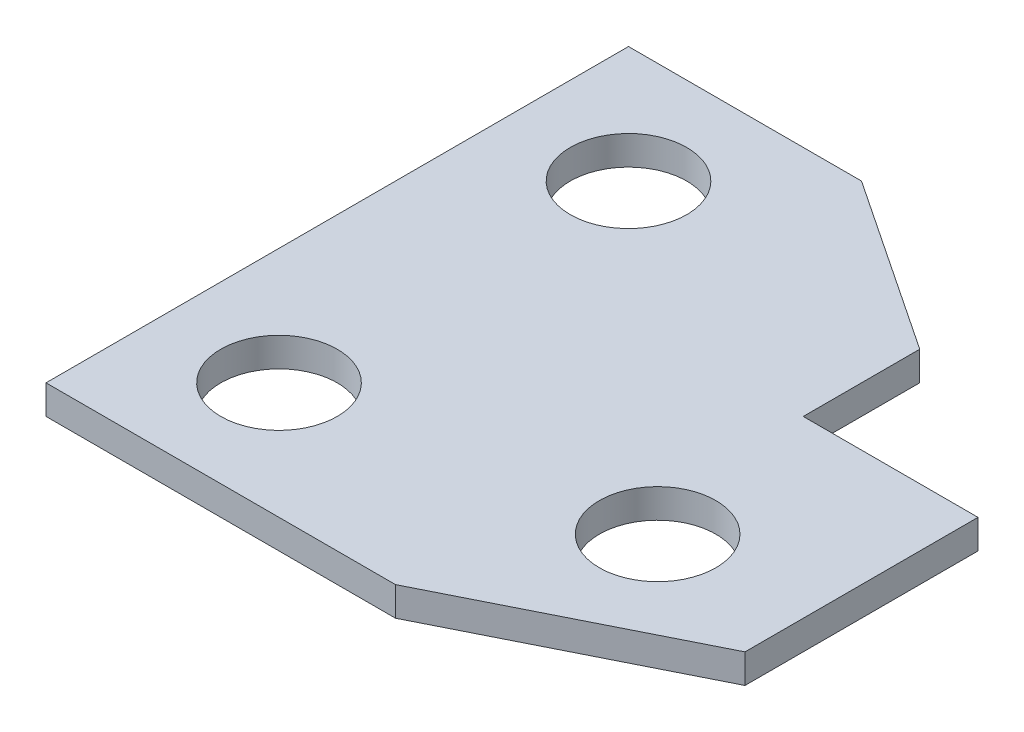
from build123d import *

# Parameters (mm, degrees)
SKETCH1_R           = 10
BOSS_EXTRUDE1_DEPTH = 5


with BuildPart() as part:
    # Sketch1 → Boss-Extrude1 (new body)
    with BuildSketch(Plane(origin=(0, 0, 0), x_dir=(1, 0, 0), z_dir=(0, 1, 0))):
        Polygon((0, 0), (60, 0), (100, 20), (100, 60), (70, 60), (70, 80), (40, 100), (0, 100), align=None)
        with Locations((20, 80)):
            Circle(SKETCH1_R, mode=Mode.SUBTRACT)
        with Locations((20, 20)):
            Circle(SKETCH1_R, mode=Mode.SUBTRACT)
        with Locations((75, 30)):
            Circle(SKETCH1_R, mode=Mode.SUBTRACT)
    extrude(amount=BOSS_EXTRUDE1_DEPTH)


solid = part.part
